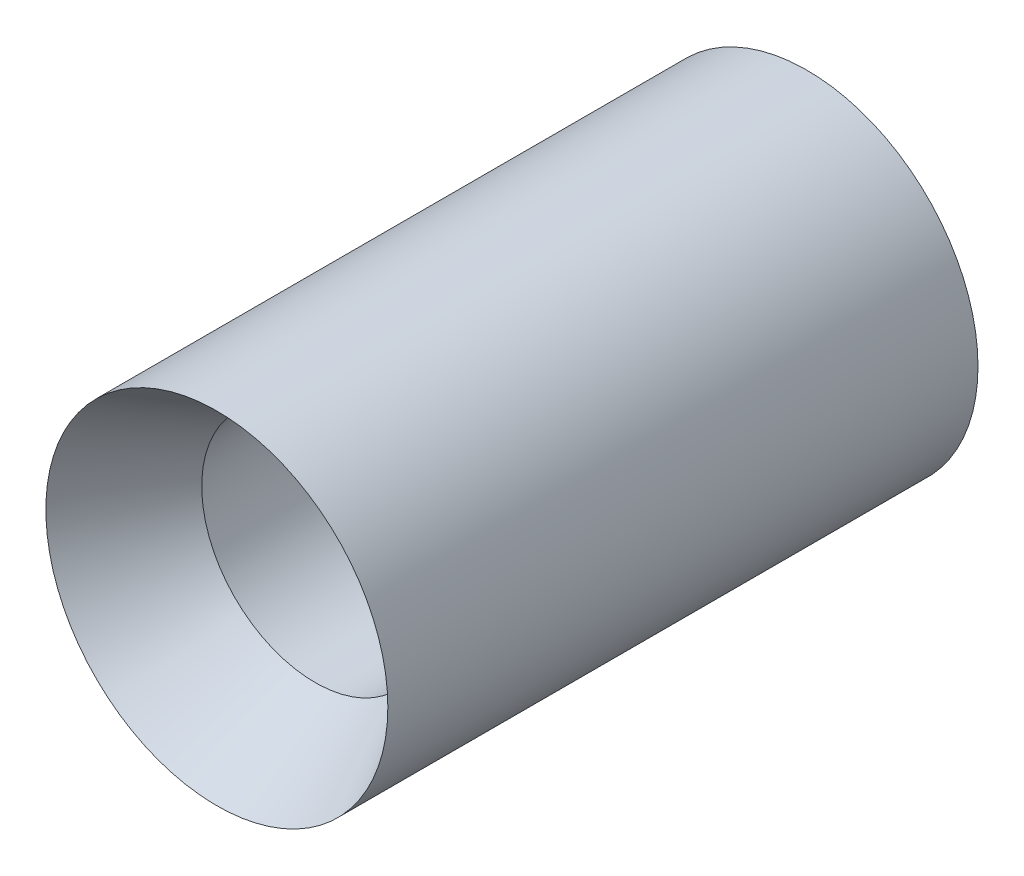
from build123d import *


with BuildPart() as part:
    # Sketch3 → Revolve1 (revolve)
    with BuildSketch(Plane(origin=(0, 0, 0), x_dir=(0, 0, -1), z_dir=(1, 0, 0))):
        Polygon((8.255, 9.525), (24.13, 9.525), (49.53, 12.720828), (49.53, 14.351), (0, 14.351), align=None)
    revolve(axis=Axis((0, 0, 0), (0, 0, -1)))


solid = part.part
